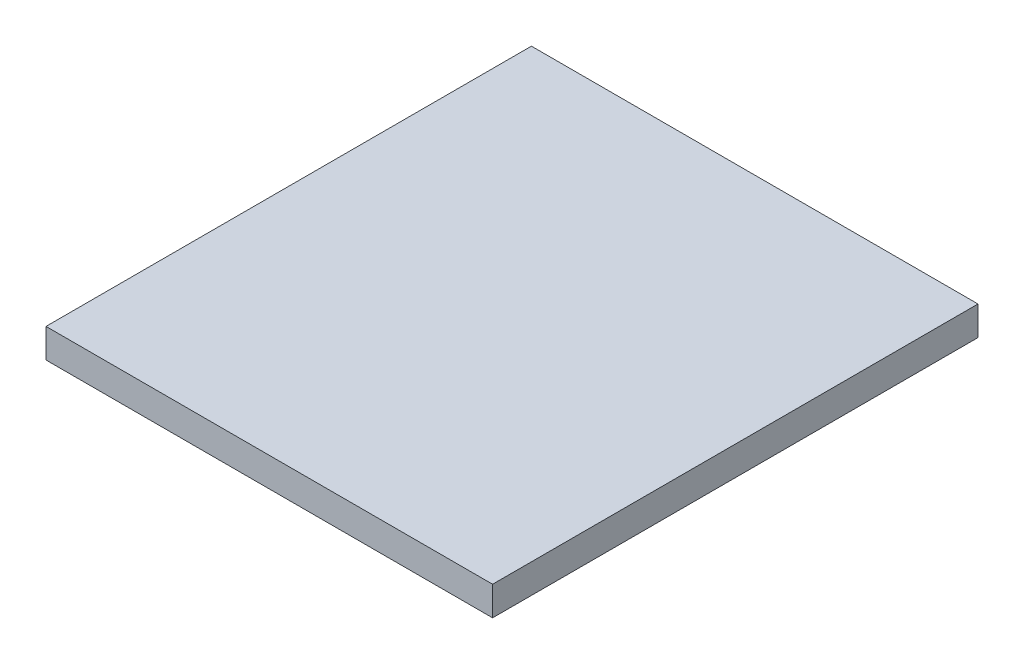
from build123d import *

# Parameters (mm, degrees)
SKETCH1_W           = 46
SKETCH1_H           = 50
BOSS_EXTRUDE1_DEPTH = 3


with BuildPart() as part:
    # Sketch1 → Boss-Extrude1 (new body)
    with BuildSketch(Plane(origin=(0, 0, 0), x_dir=(1, 0, 0), z_dir=(0, 1, 0))):
        Rectangle(SKETCH1_W, SKETCH1_H)
    extrude(amount=BOSS_EXTRUDE1_DEPTH)


solid = part.part
